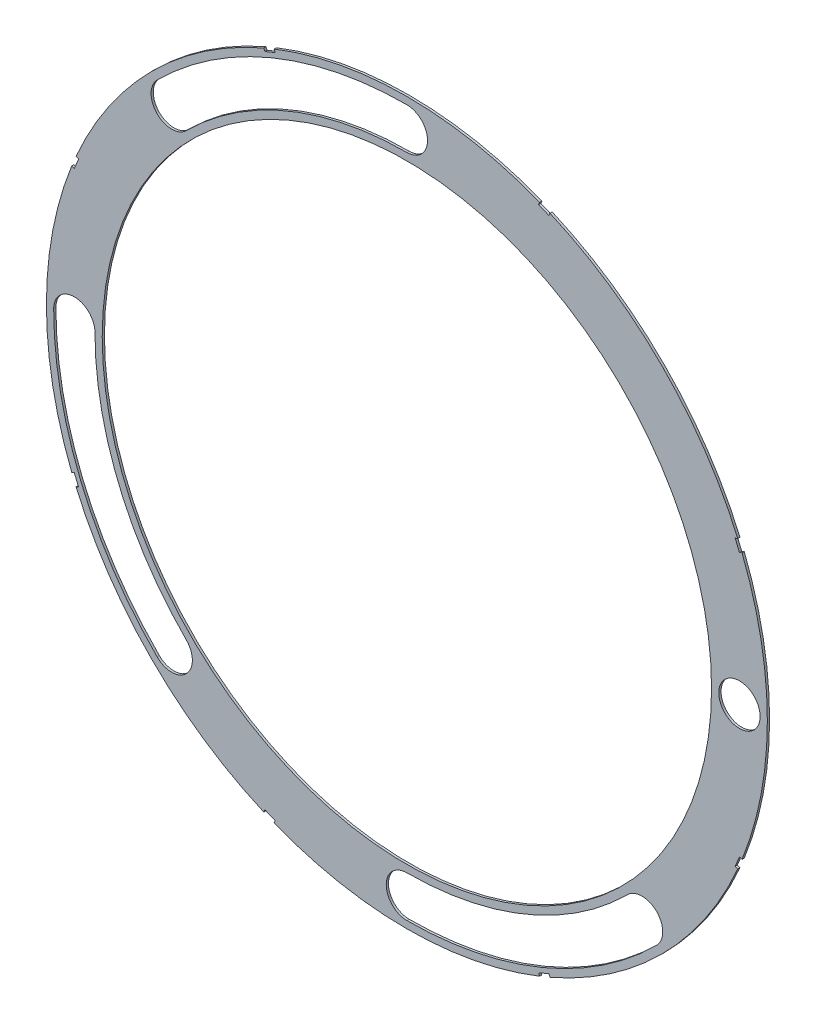
from build123d import *

# Parameters (mm, degrees)
SKETCH4_R           = 82.042
BOSS_EXTRUDE2_DEPTH = 0.508
SKETCH5_R           = 69.342
CUT_EXTRUDE5_DEPTH  = 1.508
SKETCH6_R           = 4.699
CUT_EXTRUDE6_DEPTH  = 1.508
CUT_EXTRUDE11_DEPTH = 1.508


with BuildPart() as part:
    # Sketch4 → Boss-Extrude2 (new body)
    with BuildSketch(Plane.XY):
        Circle(SKETCH4_R)
    extrude(amount=BOSS_EXTRUDE2_DEPTH)

    # Sketch5 → Cut-Extrude5 (cut, through all)
    with BuildSketch(Plane.XY.offset(0.508)):
        Circle(SKETCH5_R)
    extrude(amount=-CUT_EXTRUDE5_DEPTH, mode=Mode.SUBTRACT)

    # Sketch6 → Cut-Extrude6 (cut, through all)
    with BuildSketch(Plane.XY.offset(0.508)):
        with Locations((75.692, 0)):
            Circle(SKETCH6_R)
        with BuildLine():
            ThreePointArc((56.845020598, -56.845021895), (56.845021284, -50.199631755), (50.199631144, -50.199632289))
            ThreePointArc((50.199631144, -50.199632289), (27.167844051, -65.588980009), (-1.058e-06, -70.993))
            ThreePointArc((-1.058e-06, -70.993), (-4.699, -75.69199993), (-1.198e-06, -80.391))
            ThreePointArc((-1.198e-06, -80.391), (30.764302834, -74.271599903), (56.845020598, -56.845021895))
        make_face()
        with BuildLine():
            ThreePointArc((-56.845021895, -56.845020598), (-50.199631755, -56.845021284), (-50.199632289, -50.199631144))
            ThreePointArc((-50.199632289, -50.199631144), (-65.588980009, -27.167844051), (-70.993, 1.058e-06))
            ThreePointArc((-70.993, 1.058e-06), (-75.69199993, 4.699), (-80.391, 1.198e-06))
            ThreePointArc((-80.391, 1.198e-06), (-74.271599903, -30.764302834), (-56.845021895, -56.845020598))
        make_face()
        with BuildLine():
            ThreePointArc((-56.845020598, 56.845021895), (-56.845021284, 50.199631755), (-50.199631144, 50.199632289))
            ThreePointArc((-50.199631144, 50.199632289), (-27.167844051, 65.588980009), (1.058e-06, 70.993))
            ThreePointArc((1.058e-06, 70.993), (4.699, 75.69199993), (1.198e-06, 80.391))
            ThreePointArc((1.198e-06, 80.391), (-30.764302834, 74.271599903), (-56.845020598, 56.845021895))
        make_face()
    extrude(amount=-CUT_EXTRUDE6_DEPTH, mode=Mode.SUBTRACT)

    # Sketch8 → Cut-Extrude11 (cut, through all)
    with BuildSketch(Plane.XY.offset(0.508)):
        Polygon((76.869596069, 30.465791131), (75.89758015, 32.812445144), (74.724253144, 32.326437185), (75.696269062, 29.979783172), align=None)
        Polygon((-30.465791131, 76.869596069), (-32.812445144, 75.89758015), (-32.326437185, 74.724253144), (-29.979783172, 75.696269062), align=None)
        Polygon((-75.89758015, 32.812445144), (-76.869596069, 30.465791131), (-75.696269062, 29.979783172), (-74.724253144, 32.326437185), align=None)
        Polygon((-76.869596069, -30.465791131), (-75.89758015, -32.812445144), (-74.724253144, -32.326437185), (-75.696269062, -29.979783172), align=None)
        Polygon((-32.812445144, -75.89758015), (-30.465791131, -76.869596069), (-29.979783172, -75.696269062), (-32.326437185, -74.724253144), align=None)
        Polygon((30.465791131, -76.869596069), (32.812445144, -75.89758015), (32.326437185, -74.724253144), (29.979783172, -75.696269062), align=None)
        Polygon((75.89758015, -32.812445144), (76.869596069, -30.465791131), (75.696269062, -29.979783172), (74.724253144, -32.326437185), align=None)
        Polygon((32.812445144, 75.89758015), (30.465791131, 76.869596069), (29.979783172, 75.696269062), (32.326437185, 74.724253144), align=None)
    extrude(amount=-CUT_EXTRUDE11_DEPTH, mode=Mode.SUBTRACT)


solid = part.part
